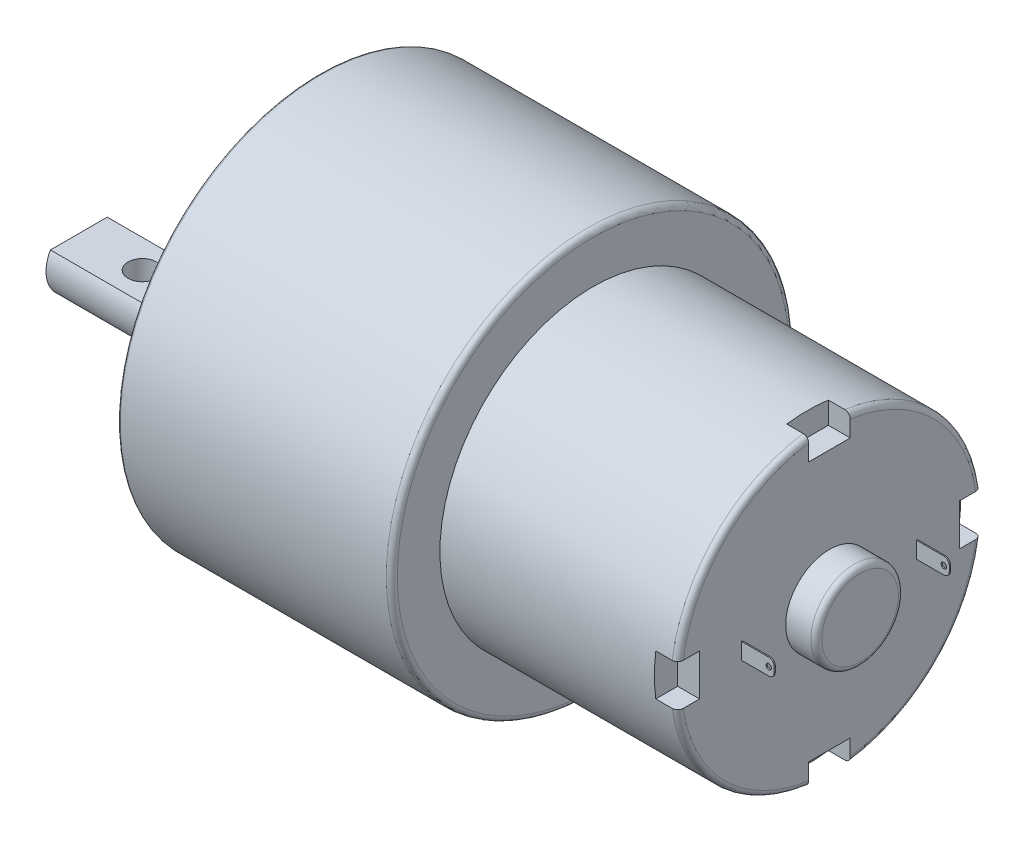
from build123d import *

# Parameters (mm, degrees)
SKETCH1_R            = 18.4
BOSS_EXTRUDE1_DEPTH  = 25
SKETCH2_R            = 1.5
CUT_EXTRUDE1_DEPTH   = 5
SKETCH4_R            = 6
BOSS_EXTRUDE2_DEPTH  = 6.5
BOSS_EXTRUDE3_DEPTH  = 15.5
CUT_EXTRUDE2_DEPTH   = 0.3
SKETCH8_R            = 14
BOSS_EXTRUDE5_DEPTH  = 21.6
FILLET3_R            = 0.2
SKETCH21_R           = 1.3
CUT_EXTRUDE8_DEPTH   = 10
CUT_EXTRUDE10_START  = -2
CUT_EXTRUDE10_DEPTH  = 2
SKETCH24_R           = 4
BOSS_EXTRUDE11_DEPTH = 2.8
SKETCH25_W           = 0.1
SKETCH25_H           = 1.5
BOSS_EXTRUDE12_DEPTH = 3
FILLET13_R           = 0.5
SKETCH26_R           = 0.25
CUT_EXTRUDE11_DEPTH  = 2
FILLET14_R           = 0.5
FILLET15_R           = 0.5
FILLET16_R           = 0.5
CUT_EXTRUDE12_START  = -14
CUT_EXTRUDE12_DEPTH  = 14


with BuildPart() as part:
    # Sketch1 → Boss-Extrude1 (new body)
    with BuildSketch(Plane(origin=(0, 0, 0), x_dir=(0, 0, -1), z_dir=(1, 0, 0))):
        Circle(SKETCH1_R)
    extrude(amount=BOSS_EXTRUDE1_DEPTH)

    # Sketch2 → Cut-Extrude1 (cut)
    with BuildSketch(Plane.ZY):
        with Locations((15.5, 0)):
            Circle(SKETCH2_R)
        with Locations((7.75, -13.423393759)):
            Circle(SKETCH2_R)
        with Locations((-7.75, -13.423393759)):
            Circle(SKETCH2_R)
        with Locations((-15.5, 0)):
            Circle(SKETCH2_R)
        with Locations((-7.75, 13.423393759)):
            Circle(SKETCH2_R)
        with Locations((7.75, 13.423393759)):
            Circle(SKETCH2_R)
    extrude(amount=-CUT_EXTRUDE1_DEPTH, mode=Mode.SUBTRACT)

    # Sketch4 → Boss-Extrude2 (add)
    with BuildSketch(Plane.ZY):
        with Locations((0, -6.8)):
            Circle(SKETCH4_R)
    extrude(amount=BOSS_EXTRUDE2_DEPTH)

    # Sketch5 → Boss-Extrude3 (add)
    with BuildSketch(Plane.ZY.offset(6.5)):
        with BuildLine():
            ThreePointArc((-1.353991294, -4.122929292), (0, -9.8), (1.353991294, -4.122929292))
            ThreePointArc((1.353991294, -4.122929292), (0, -3.8), (-1.353991294, -4.122929292))
        make_face()
    extrude(amount=BOSS_EXTRUDE3_DEPTH)

    # Sketch7 → Cut-Extrude2 (cut)
    with BuildSketch(Plane.ZY):
        with BuildLine():
            ThreePointArc((7.830229882, -9.09326674), (0, 12), (-7.830229882, -9.09326674))
            ThreePointArc((-7.830229882, -9.09326674), (0, 1.754809472), (7.830229882, -9.09326674))
        make_face()
    extrude(amount=-CUT_EXTRUDE2_DEPTH, mode=Mode.SUBTRACT)

    # Sketch8 → Boss-Extrude5 (add)
    with BuildSketch(Plane(origin=(25, 0, 0), x_dir=(0, 0, -1), z_dir=(1, 0, 0))):
        Circle(SKETCH8_R)
    extrude(amount=BOSS_EXTRUDE5_DEPTH)

    # Fillet3
    fillet3_edges = [part.edges().sort_by_distance(p)[0] for p in [
        (0, 0, 18.4),
        (-6.5, -6.8, -6),
        (0, -13.423393759, 6.25),
        (0, 0, 14),
        (0, -13.423393759, -9.25),
        (0, 0, -17),
        (0, 13.423393759, -9.25),
        (0, 13.423393759, 6.25),
    ]]
    fillet(fillet3_edges, radius=FILLET3_R)

    # Sketch21 → Cut-Extrude8 (cut, symmetric)
    with BuildSketch(Plane(origin=(0, 0, 0), x_dir=(1, 0, 0), z_dir=(0, 1, 0))):
        with Locations((-16.2, 0)):
            Circle(SKETCH21_R)
    extrude(amount=CUT_EXTRUDE8_DEPTH, both=True, mode=Mode.SUBTRACT)

    # Sketch23 → Cut-Extrude10 (cut)
    with BuildSketch(Plane(origin=(46.6, 0, 0), x_dir=(0, 0, -1), z_dir=(1, 0, 0)).offset(CUT_EXTRUDE10_START)):
        with BuildLine():
            Line((-1.9, 13.870472234), (-1.9, 11.870472234))
            Line((-1.9, 11.870472234), (1.9, 11.870472234))
            Line((1.9, 11.870472234), (1.9, 13.870472234))
            ThreePointArc((1.9, 13.870472234), (0, 14), (-1.9, 13.870472234))
        make_face()
        with BuildLine():
            Line((13.870472234, 1.9), (11.870472234, 1.9))
            Line((11.870472234, 1.9), (11.870472234, -1.9))
            Line((11.870472234, -1.9), (13.870472234, -1.9))
            ThreePointArc((13.870472234, -1.9), (14, 0), (13.870472234, 1.9))
        make_face()
        with BuildLine():
            Line((1.9, -13.870472234), (1.9, -11.870472234))
            Line((1.9, -11.870472234), (-1.9, -11.870472234))
            Line((-1.9, -11.870472234), (-1.9, -13.870472234))
            ThreePointArc((-1.9, -13.870472234), (0, -14), (1.9, -13.870472234))
        make_face()
        with BuildLine():
            Line((-13.870472234, -1.9), (-11.870472234, -1.9))
            Line((-11.870472234, -1.9), (-11.870472234, 1.9))
            Line((-11.870472234, 1.9), (-13.870472234, 1.9))
            ThreePointArc((-13.870472234, 1.9), (-14, 0), (-13.870472234, -1.9))
        make_face()
    extrude(amount=CUT_EXTRUDE10_DEPTH, mode=Mode.SUBTRACT)

    # Sketch24 → Boss-Extrude11 (add)
    with BuildSketch(Plane(origin=(46.6, 0, 0), x_dir=(0, 0, -1), z_dir=(1, 0, 0))):
        Circle(SKETCH24_R)
    extrude(amount=BOSS_EXTRUDE11_DEPTH)

    # Sketch25 → Boss-Extrude12 (add)
    with BuildSketch(Plane(origin=(46.6, 0, 0), x_dir=(0, 0, -1), z_dir=(1, 0, 0))):
        with Locations((8, 0)):
            Rectangle(SKETCH25_W, SKETCH25_H)
        with Locations((-8, 0)):
            Rectangle(SKETCH25_W, SKETCH25_H)
    extrude(amount=BOSS_EXTRUDE12_DEPTH)

    # Fillet13
    fillet13_edges = [part.edges().sort_by_distance(p)[0] for p in [
        (49.6, 0.75, -8),
        (49.6, -0.75, -8),
        (49.6, 0.75, 8),
        (49.6, -0.75, 8),
    ]]
    fillet(fillet13_edges, radius=FILLET13_R)

    # Sketch26 → Cut-Extrude11 (cut)
    with BuildSketch(Plane.XY.offset(8.05)):
        with Locations((49.1, 0)):
            Circle(SKETCH26_R)
    cut_extrude11 = extrude(amount=-CUT_EXTRUDE11_DEPTH, mode=Mode.SUBTRACT)

    # Mirror1: Cut-Extrude11 across plane
    add(cut_extrude11.mirror(Plane.XY), mode=Mode.SUBTRACT)

    # Fillet14
    fillet14_edges = [part.edges().sort_by_distance(p)[0] for p in [
        (49.4, 0, 4),
    ]]
    fillet(fillet14_edges, radius=FILLET14_R)

    # Fillet15
    fillet15_edges = [part.edges().sort_by_distance(p)[0] for p in [
        (46.6, -9.899494937, -9.899494937),
        (46.6, -9.899494937, 9.899494937),
        (46.6, 9.899494937, -9.899494937),
        (46.6, 9.899494937, 9.899494937),
    ]]
    fillet(fillet15_edges, radius=FILLET15_R)

    # Fillet16
    fillet16_edges = [part.edges().sort_by_distance(p)[0] for p in [
        (25, 0, 18.4),
    ]]
    fillet(fillet16_edges, radius=FILLET16_R)

    # Sketch27 → Cut-Extrude12 (cut)
    with BuildSketch(Plane.ZY.offset(22).offset(CUT_EXTRUDE12_START)):
        with BuildLine():
            Line((-2.598076211, -5.3), (2.598076211, -5.3))
            ThreePointArc((2.598076211, -5.3), (0, -3.8), (-2.598076211, -5.3))
        make_face()
    extrude(amount=CUT_EXTRUDE12_DEPTH, mode=Mode.SUBTRACT)


solid = part.part
